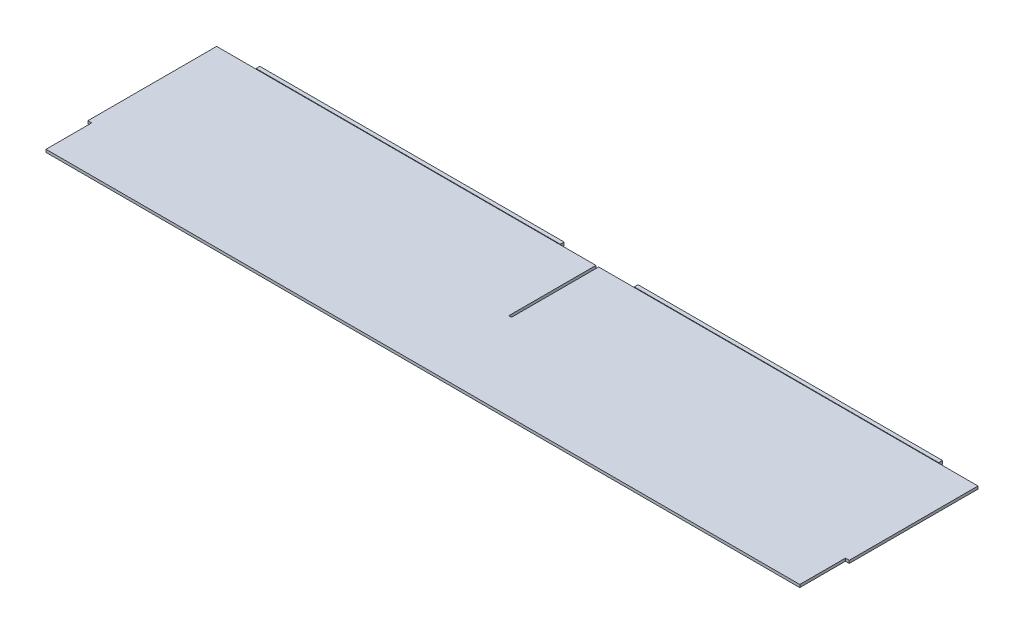
from build123d import *

# Parameters (mm, degrees)
SKETCH1_W           = 635.3556
SKETCH1_H           = 145.542
BOSS_EXTRUDE1_DEPTH = 1.143
SKETCH2_W           = 254
SKETCH2_H           = 2.7305
BOSS_EXTRUDE2_DEPTH = 3.175
SKETCH3_W           = 3.175
SKETCH3_H           = 38.1
CUT_EXTRUDE1_DEPTH  = 3.7305
SKETCH4_W           = 2.286
SKETCH4_H           = 72.771
CUT_EXTRUDE2_DEPTH  = 3.7305


with BuildPart() as part:
    # Sketch1 → Boss-Extrude1 (new body, symmetric)
    with BuildSketch(Plane(origin=(0, 0, 0), x_dir=(1, 0, 0), z_dir=(0, 1, 0))):
        Rectangle(SKETCH1_W, SKETCH1_H)
    extrude(amount=BOSS_EXTRUDE1_DEPTH, both=True)

    # Sketch2 → Boss-Extrude2 (add)
    with BuildSketch(Plane(origin=(0, 0, -72.771), x_dir=(-1, 0, 0), z_dir=(0, 0, -1))):
        with Locations((-157.8229, 0.22225)):
            Rectangle(SKETCH2_W, SKETCH2_H)
        with Locations((157.8229, 0.22225)):
            Rectangle(SKETCH2_W, SKETCH2_H)
    extrude(amount=BOSS_EXTRUDE2_DEPTH)

    # Sketch3 → Cut-Extrude1 (cut, through all)
    with BuildSketch(Plane.XZ.offset(1.143)):
        with Locations((-316.0903, 53.721)):
            Rectangle(SKETCH3_W, SKETCH3_H)
    cut_extrude1 = extrude(amount=-CUT_EXTRUDE1_DEPTH, mode=Mode.SUBTRACT)

    # Mirror1: Cut-Extrude1 across plane
    add(cut_extrude1.mirror(Plane(origin=(0, 0, 0), x_dir=(0, 0, 1), z_dir=(1, 0, 0))), mode=Mode.SUBTRACT)

    # Sketch4 → Cut-Extrude2 (cut, through all)
    with BuildSketch(Plane.XZ.offset(1.143)):
        with Locations((0, -36.3855)):
            Rectangle(SKETCH4_W, SKETCH4_H)
    extrude(amount=-CUT_EXTRUDE2_DEPTH, mode=Mode.SUBTRACT)


solid = part.part
